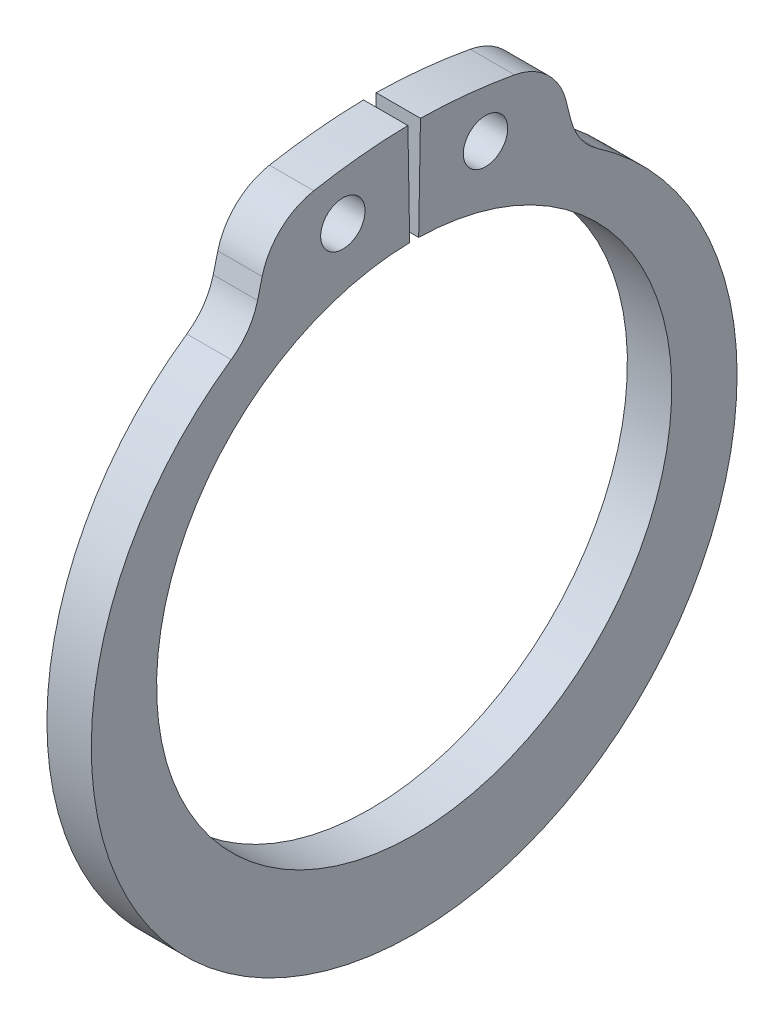
from build123d import *

# Parameters (mm, degrees)
SKETCH1_R      = 0.9906
EXTRUDE1_DEPTH = 0.9906
FILLET1_R      = 2.921


with BuildPart() as part:
    # Sketch1 → Extrude1 (new body, symmetric)
    with BuildSketch(Plane(origin=(0, 0, 0), x_dir=(0, 0, -1), z_dir=(1, 0, 0))):
        with BuildLine():
            Line((-0.200810879, 11.50444755), (-0.280603281, 16.075751212))
            ThreePointArc((-0.280603281, 16.075751212), (-3.342127668, 15.838850739), (-6.35354883, 15.238520836))
            Line((-6.35354883, 15.238520836), (-7.276503528, 11.536751728))
            ThreePointArc((-7.276503528, 11.536751728), (0, -15.3416), (7.276503528, 11.536751728))
            Line((7.276503528, 11.536751728), (6.35354883, 15.238520836))
            ThreePointArc((6.35354883, 15.238520836), (3.342127668, 15.838850739), (0.280603281, 16.075751212))
            Line((0.280603281, 16.075751212), (0.200810879, 11.50444755))
            ThreePointArc((0.200810879, 11.50444755), (0, -11.5062), (-0.200810879, 11.50444755))
        make_face()
        with Locations((-3.18562375, 13.738695669)):
            Circle(SKETCH1_R, mode=Mode.SUBTRACT)
        with Locations((3.18562375, 13.738695669)):
            Circle(SKETCH1_R, mode=Mode.SUBTRACT)
    extrude(amount=EXTRUDE1_DEPTH, both=True)

    # Fillet1
    fillet1_edges = [part.edges().sort_by_distance(p)[0] for p in [
        (0, 15.238520836, -6.35354883),
        (0, 11.536751728, -7.276503528),
        (0, 11.536751728, 7.276503528),
        (0, 15.238520836, 6.35354883),
    ]]
    fillet(fillet1_edges, radius=FILLET1_R)


solid = part.part
